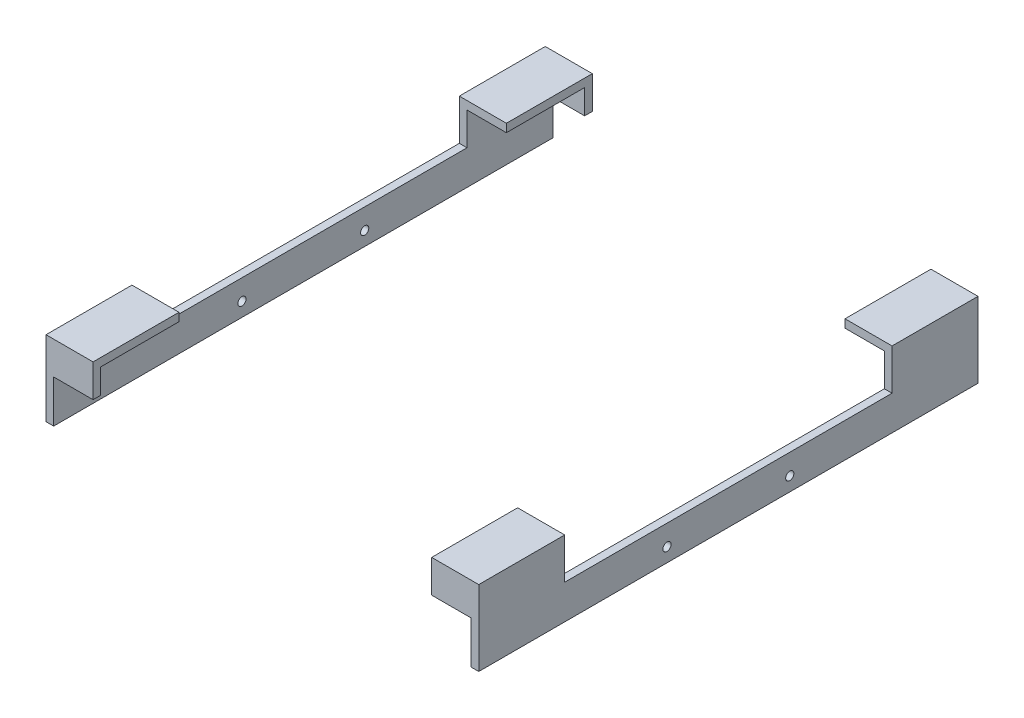
from build123d import *

# Parameters (mm, degrees)
BOSS_EXTRUDE1_DEPTH        = 154.94
BOSS_EXTRUDE1_DEPTH_BACK   = 154.94
BOSS_EXTRUDE1_2_DEPTH      = 154.94
BOSS_EXTRUDE1_2_DEPTH_BACK = 154.94
SKETCH3_W                  = 29.21
SKETCH3_H                  = 20.32
BOSS_EXTRUDE2_DEPTH        = 4.7625
SKETCH4_W                  = 29.21
SKETCH4_H                  = 20.32
BOSS_EXTRUDE3_DEPTH        = 4.7625
SKETCH5_W                  = 29.21
SKETCH5_H                  = 25.4
CUT_EXTRUDE1_DEPTH         = 101.6
CUT_EXTRUDE1_DEPTH_BACK    = 101.6
SKETCH6_R                  = 2.54
CUT_EXTRUDE3_DEPTH         = 269.605
SKETCH7_W                  = 309.88
SKETCH7_H                  = 4.050329793
CUT_EXTRUDE4_DEPTH         = 269.605


with BuildPart() as part:
    # Sketch2 → Boss-Extrude1 (new body, two sides)
    with BuildSketch(Plane.XY) as boss_extrude1_sk:
        Polygon((-129.54, 0), (-129.54, 45.72), (-105.0925, 45.72), (-105.0925, 50.8), (-134.3025, 50.8), (-134.3025, 0), align=None)
    extrude(amount=BOSS_EXTRUDE1_DEPTH)
    extrude(boss_extrude1_sk.sketch, amount=-BOSS_EXTRUDE1_DEPTH_BACK)



with BuildPart() as body_2:
    # Sketch2 → Boss-Extrude1 2 (new body, two sides)
    with BuildSketch(Plane.XY) as boss_extrude1_2_sk:
        Polygon((105.0925, 45.72), (105.0925, 50.8), (134.3025, 50.8), (134.3025, 0), (129.54, 0), (129.54, 45.72), align=None)
    extrude(amount=BOSS_EXTRUDE1_2_DEPTH)
    extrude(boss_extrude1_2_sk.sketch, amount=-BOSS_EXTRUDE1_2_DEPTH_BACK)


with BuildPart() as part_1:
    add(part.part)

    add(body_2.part)  # Boss-Extrude2 merges body 2
    # Sketch3 → Boss-Extrude2 (add)
    with BuildSketch(Plane.XY.offset(154.94)):
        with Locations((-119.6975, 40.64)):
            Rectangle(SKETCH3_W, SKETCH3_H)
        with Locations((119.6975, 40.64)):
            Rectangle(SKETCH3_W, SKETCH3_H)
    extrude(amount=-BOSS_EXTRUDE2_DEPTH)

    # Sketch4 → Boss-Extrude3 (add)
    with BuildSketch(Plane(origin=(0, 0, -154.94), x_dir=(-1, 0, 0), z_dir=(0, 0, -1))):
        with Locations((119.6975, 40.64)):
            Rectangle(SKETCH4_W, SKETCH4_H)
        with Locations((-119.6975, 40.64)):
            Rectangle(SKETCH4_W, SKETCH4_H)
    extrude(amount=-BOSS_EXTRUDE3_DEPTH)

    # Sketch5 → Cut-Extrude1 (cut, two sides)
    with BuildSketch(Plane.XY) as cut_extrude1_sk:
        with Locations((119.6975, 38.1)):
            Rectangle(SKETCH5_W, SKETCH5_H)
        with Locations((-119.6975, 38.1)):
            Rectangle(SKETCH5_W, SKETCH5_H)
    extrude(amount=CUT_EXTRUDE1_DEPTH, mode=Mode.SUBTRACT)
    extrude(cut_extrude1_sk.sketch, amount=-CUT_EXTRUDE1_DEPTH_BACK, mode=Mode.SUBTRACT)

    # Sketch6 → Cut-Extrude3 (cut, through all)
    with BuildSketch(Plane.ZY.offset(134.3025)):
        with Locations((38.1, 12.7)):
            Circle(SKETCH6_R)
        with Locations((-38.1, 12.7)):
            Circle(SKETCH6_R)
    extrude(amount=-CUT_EXTRUDE3_DEPTH, mode=Mode.SUBTRACT)

    # Sketch7 → Cut-Extrude4 (cut, through all)
    with BuildSketch(Plane(origin=(134.3025, 0, 0), x_dir=(0, 0, -1), z_dir=(1, 0, 0))):
        with Locations((0, 2.025164897)):
            Rectangle(SKETCH7_W, SKETCH7_H)
    extrude(amount=-CUT_EXTRUDE4_DEPTH, mode=Mode.SUBTRACT)


solid = part_1.part
